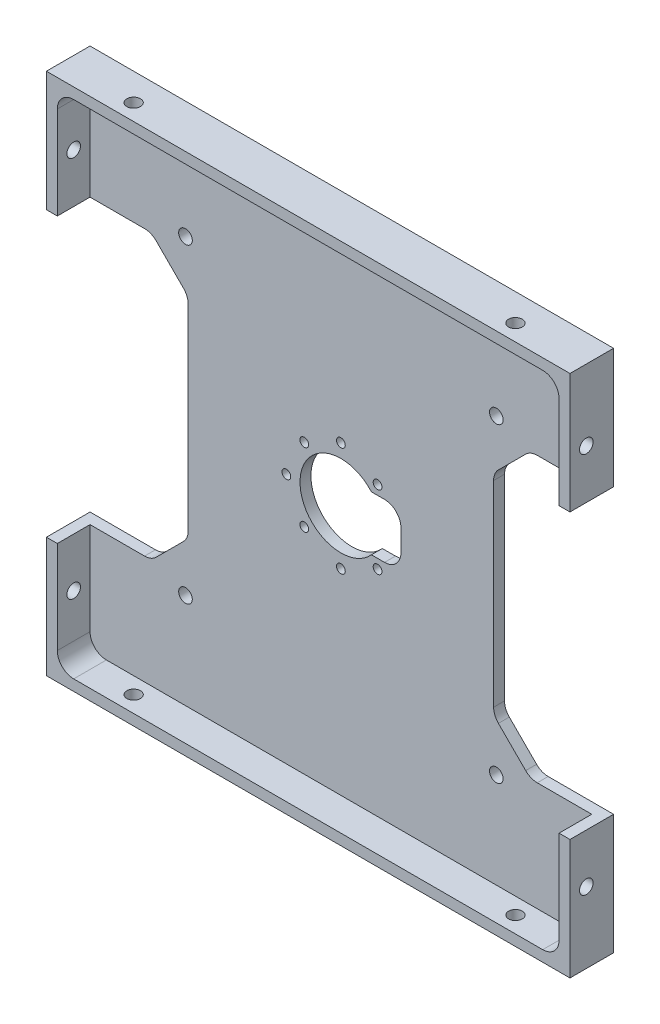
from build123d import *

# Parameters (mm, degrees)
SKETCH1_W                      = 96
SKETCH1_H                      = 96
BOSS_EXTRUDE1_DEPTH            = 8
SKETCH2_W                      = 92
SKETCH2_H                      = 92
COMPONENT_PLATFORM_DEPTH       = 6
CABLE_SLOTS_DEPTH              = 6
SKETCH4_R                      = 7.5
CENTER_MASS_CUT_DEPTH          = 6
INNER_CORNER_FILLETS_R         = 3
SKETCH10_W                     = 11
SKETCH10_H                     = 10
MOTOR_CUTOUT_DEPTH             = 2
FILLET1_R                      = 3
M3X0_5_TAPPED_HOLE1_AT_2_COUNT = 2
M3X0_5_TAPPED_HOLE1_AT_2_PITCH = 70
M3X0_5_TAPPED_HOLE2_AT_2_COUNT = 2
M3X0_5_TAPPED_HOLE2_AT_2_PITCH = 70
M2X0_4_TAPPED_HOLE1_D          = 1.6
M2X0_4_TAPPED_HOLE1_DEPTH      = 5.2
M2X0_4_TAPPED_HOLE1_TIP        = 0.480688495


with BuildPart() as part:
    # Sketch1 → Boss-Extrude1 (new body)
    with BuildSketch(Plane.XY):
        Rectangle(SKETCH1_W, SKETCH1_H)
    extrude(amount=BOSS_EXTRUDE1_DEPTH)

    # Sketch2 → Component Platform (cut)
    with BuildSketch(Plane.XY.offset(8)):
        Rectangle(SKETCH2_W, SKETCH2_H)
    extrude(amount=-COMPONENT_PLATFORM_DEPTH, mode=Mode.SUBTRACT)

    # Sketch3 → Cable Slots (cut, symmetric)
    with BuildSketch(Plane.XY.offset(2)):
        with BuildLine():
            Line((-33.878679656, -25.121320344), (-28.878679656, -20.121320344))
            ThreePointArc((-28.878679656, -20.121320344), (-28.228361402, -19.148050297), (-28, -18))
            Line((-28, -18), (-28, 18))
            ThreePointArc((-28, 18), (-28.228361402, 19.148050297), (-28.878679656, 20.121320344))
            Line((-28.878679656, 20.121320344), (-33.878679656, 25.121320344))
            ThreePointArc((-33.878679656, 25.121320344), (-34.851949703, 25.771638598), (-36, 26))
            Line((-36, 26), (-48, 26))
            Line((-48, 26), (-48, -26))
            Line((-48, -26), (-36, -26))
            ThreePointArc((-36, -26), (-34.851949703, -25.771638598), (-33.878679656, -25.121320344))
        make_face()
        with BuildLine():
            Line((48, -26), (48, 26))
            Line((48, 26), (36, 26))
            ThreePointArc((36, 26), (34.851949703, 25.771638598), (33.878679656, 25.121320344))
            Line((33.878679656, 25.121320344), (28.878679656, 20.121320344))
            ThreePointArc((28.878679656, 20.121320344), (28.228361402, 19.148050297), (28, 18))
            Line((28, 18), (28, -18))
            ThreePointArc((28, -18), (28.228361402, -19.148050297), (28.878679656, -20.121320344))
            Line((28.878679656, -20.121320344), (33.878679656, -25.121320344))
            ThreePointArc((33.878679656, -25.121320344), (34.851949703, -25.771638598), (36, -26))
            Line((36, -26), (48, -26))
        make_face()
    extrude(amount=CABLE_SLOTS_DEPTH, both=True, mode=Mode.SUBTRACT)

    # Sketch4 → Center Mass Cut (cut)
    with BuildSketch(Plane.XY.offset(2)):
        Circle(SKETCH4_R)
    extrude(amount=-CENTER_MASS_CUT_DEPTH, mode=Mode.SUBTRACT)

    # Inner Corner Fillets
    inner_corner_fillets_edges = [part.edges().sort_by_distance(p)[0] for p in [
        (-46, -46, 5),
        (-46, 46, 5),
        (46, 46, 5),
        (46, -46, 5),
    ]]
    fillet(inner_corner_fillets_edges, radius=INNER_CORNER_FILLETS_R)

    # Sketch10 → Motor Cutout (cut)
    with BuildSketch(Plane.XY.offset(2)):
        with Locations((5.5, 0)):
            Rectangle(SKETCH10_W, SKETCH10_H)
    extrude(amount=-MOTOR_CUTOUT_DEPTH, mode=Mode.SUBTRACT)

    # Fillet1
    fillet1_edges = [part.edges().sort_by_distance(p)[0] for p in [
        (11, -5, 1),
        (11, 5, 1),
    ]]
    fillet(fillet1_edges, radius=FILLET1_R)

    # Sketch14 → M3x0.5 Tapped Hole1 (revolve, cut)
    with BuildSketch(Plane(origin=(48, -35, 5), x_dir=(0, 0, -1), z_dir=(0, 1, 0))):
        Polygon((0, 0), (0, 8.251075774), (1.25, 7.5), (1.25, 0), align=None)
    m3x0_5_tapped_hole1 = revolve(axis=Axis((54.35, -35, 5), (-1, 0, 0)), mode=Mode.SUBTRACT)

    # M3x0.5 Tapped Hole1 at 2: M3x0.5 Tapped Hole1 ×2
    with Locations(*[(0, i * M3X0_5_TAPPED_HOLE1_AT_2_PITCH, 0) for i in range(1, M3X0_5_TAPPED_HOLE1_AT_2_COUNT)]):
        add(m3x0_5_tapped_hole1, mode=Mode.SUBTRACT)

    # Sketch17 → M3x0.5 Tapped Hole2 (revolve, cut)
    with BuildSketch(Plane(origin=(35, 48, 5), x_dir=(0, 0, 1), z_dir=(1, 0, 0))):
        Polygon((0, 0), (0, 8.251075774), (1.25, 7.5), (1.25, 0), align=None)
    m3x0_5_tapped_hole2 = revolve(axis=Axis((35, 54.35, 5), (0, -1, 0)), mode=Mode.SUBTRACT)

    # M3x0.5 Tapped Hole2 at 2: M3x0.5 Tapped Hole2 ×2
    with Locations(*[(-i * M3X0_5_TAPPED_HOLE2_AT_2_PITCH, 0, 0) for i in range(1, M3X0_5_TAPPED_HOLE2_AT_2_COUNT)]):
        add(m3x0_5_tapped_hole2, mode=Mode.SUBTRACT)

    # Mirror1: M3x0.5 Tapped Hole1 across plane
    add(m3x0_5_tapped_hole1.mirror(Plane(origin=(0, 0, 0), x_dir=(0, 0, 1), z_dir=(1, 0, 0))), mode=Mode.SUBTRACT)

    # Mirror1 copy 1 sketch → Mirror1 copy 1 (revolve, cut)
    with BuildSketch(Plane(origin=(-48, 35, 5), x_dir=(0, 0, -1), z_dir=(0, 1, 0))):
        Polygon((0, 0), (0, -8.251075774), (1.25, -7.5), (1.25, 0), align=None)
    revolve(axis=Axis((-54.35, 35, 5), (-1, 0, 0)), mode=Mode.SUBTRACT)

    # Mirror2: M3x0.5 Tapped Hole2 across plane
    add(m3x0_5_tapped_hole2.mirror(Plane(origin=(0, 0, 0), x_dir=(0, 0, 1), z_dir=(0, -1, 0))), mode=Mode.SUBTRACT)

    # Mirror2 copy 1 sketch → Mirror2 copy 1 (revolve, cut)
    with BuildSketch(Plane(origin=(-35, -48, 5), x_dir=(0, 0, 1), z_dir=(1, 0, 0))):
        Polygon((0, 0), (0, -8.251075774), (1.25, -7.5), (1.25, 0), align=None)
    revolve(axis=Axis((-35, -54.35, 5), (0, -1, 0)), mode=Mode.SUBTRACT)

    # Sketch20 → M3x0.5 Tapped Hole3 (revolve, cut)
    with BuildSketch(Plane(origin=(-28.5, -28.5, 2), x_dir=(0, -1, 0), z_dir=(1, 0, 0))):
        Polygon((0, 0), (0, 8.251075774), (1.25, 7.5), (1.25, 0), align=None)
    m3x0_5_tapped_hole3 = revolve(axis=Axis((-28.5, -28.5, 8.35), (0, 0, -1)), mode=Mode.SUBTRACT)

    # Mirror3: M3x0.5 Tapped Hole3 across plane
    add(m3x0_5_tapped_hole3.mirror(Plane(origin=(0, 0, 0), x_dir=(0, 0, 1), z_dir=(1, 0, 0))), mode=Mode.SUBTRACT)

    # Mirror4: M3x0.5 Tapped Hole3 across plane
    add(m3x0_5_tapped_hole3.mirror(Plane.ZX), mode=Mode.SUBTRACT)

    # Mirror4 copy 1 sketch → Mirror4 copy 1 (revolve, cut)
    with BuildSketch(Plane(origin=(28.5, 28.5, 2), x_dir=(0, 1, 0), z_dir=(-1, 0, 0))):
        Polygon((0, 0), (0, 8.251075774), (1.25, 7.5), (1.25, 0), align=None)
    revolve(axis=Axis((28.5, 28.5, 8.35), (0, 0, -1)), mode=Mode.SUBTRACT)

    # M2x0.4 Tapped Hole1
    with Locations(Plane.XY.offset(2)):
        with Locations((6.72, -6.72), (0, -10), (-6.72, -6.72), (-10, 0), (-6.72, 6.72), (0, 10), (6.72, 6.72)):
            Hole(M2X0_4_TAPPED_HOLE1_D / 2, depth=M2X0_4_TAPPED_HOLE1_DEPTH)
            with Locations((0, 0, -(M2X0_4_TAPPED_HOLE1_DEPTH + M2X0_4_TAPPED_HOLE1_TIP / 2))):  # 118° drill point
                Cone(0, M2X0_4_TAPPED_HOLE1_D / 2, M2X0_4_TAPPED_HOLE1_TIP, mode=Mode.SUBTRACT)


solid = part.part
